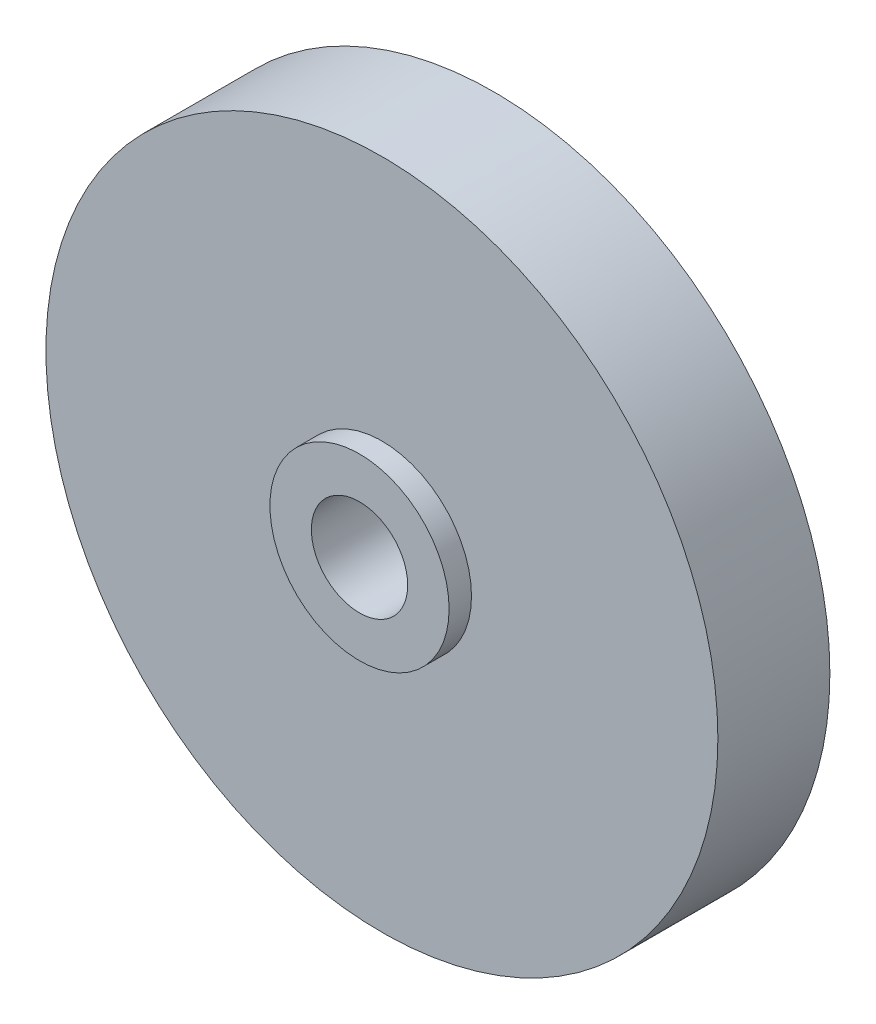
from build123d import *

# Parameters (mm, degrees)
SKETCH1_R           = 30
SKETCH1_R_2         = 4.3
BOSS_EXTRUDE1_DEPTH = 12
SKETCH2_R           = 7.25
CUT_EXTRUDE1_DEPTH  = 5
SKETCH3_R           = 30
SKETCH3_R_2         = 8
CUT_EXTRUDE2_DEPTH  = 2


with BuildPart() as part:
    # Sketch1 → Boss-Extrude1 (new body)
    with BuildSketch(Plane.XY):
        Circle(SKETCH1_R)
        Circle(SKETCH1_R_2, mode=Mode.SUBTRACT)
    extrude(amount=BOSS_EXTRUDE1_DEPTH)

    # Sketch2 → Cut-Extrude1 (cut)
    with BuildSketch(Plane.XY):
        Circle(SKETCH2_R)
    extrude(amount=CUT_EXTRUDE1_DEPTH, mode=Mode.SUBTRACT)

    # Sketch3 → Cut-Extrude2 (cut)
    with BuildSketch(Plane.XY.offset(12)):
        Circle(SKETCH3_R)
        Circle(SKETCH3_R_2, mode=Mode.SUBTRACT)
    extrude(amount=-CUT_EXTRUDE2_DEPTH, mode=Mode.SUBTRACT)


solid = part.part
